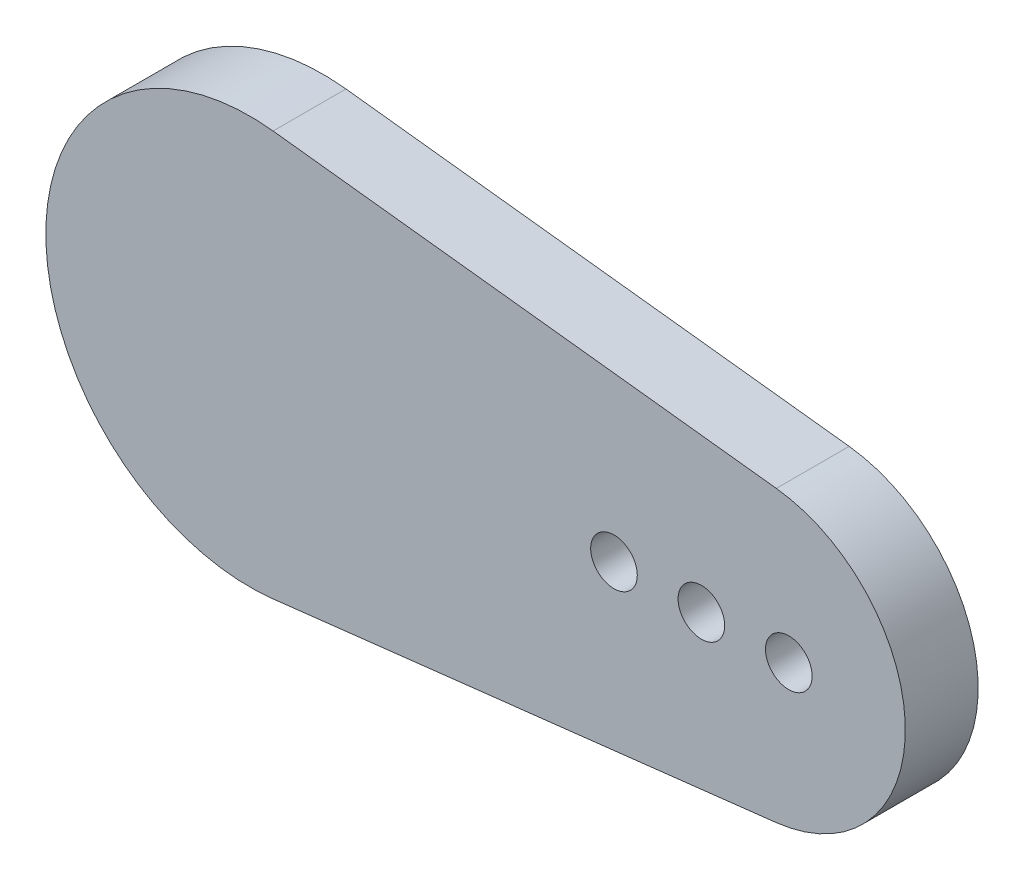
from build123d import *

# Parameters (mm, degrees)
SKETCH1_R           = 0.8
BOSS_EXTRUDE1_DEPTH = 2.5


with BuildPart() as part:
    # Sketch1 → Boss-Extrude1 (new body)
    with BuildSketch(Plane.XY):
        with BuildLine():
            Line((0.8, -6.95413546), (18.071428571, -4.967239614))
            ThreePointArc((18.071428571, -4.967239614), (22.5, 0), (18.071428571, 4.967239614))
            Line((18.071428571, 4.967239614), (0.8, 6.95413546))
            ThreePointArc((0.8, 6.95413546), (-7, 0), (0.8, -6.95413546))
        make_face()
        with Locations((12.5, 0)):
            Circle(SKETCH1_R, mode=Mode.SUBTRACT)
        with Locations((15.5, 0)):
            Circle(SKETCH1_R, mode=Mode.SUBTRACT)
        with Locations((18.5, 0)):
            Circle(SKETCH1_R, mode=Mode.SUBTRACT)
    extrude(amount=BOSS_EXTRUDE1_DEPTH)


solid = part.part
